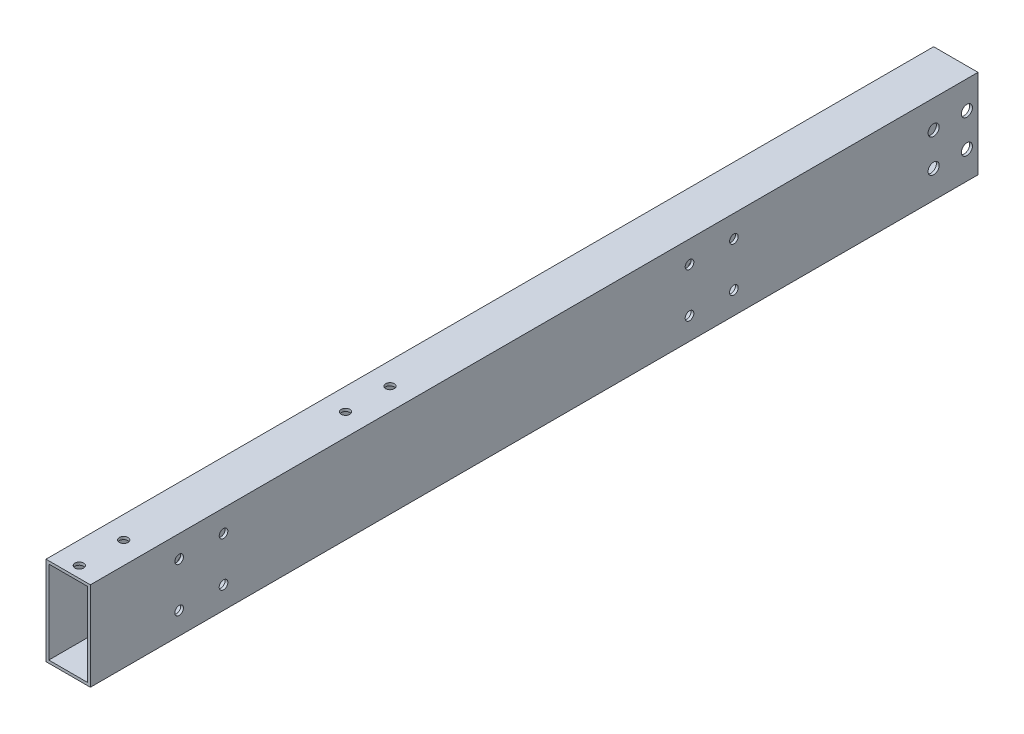
from build123d import *

# Parameters (mm, degrees)
SKETCH1_W           = 25.4
SKETCH1_H           = 50.8
SKETCH1_W_2         = 22.225
SKETCH1_H_2         = 47.625
EXTRUDE_THIN1_DEPTH = 508
SKETCH2_R           = 2.4765
CUT_EXTRUDE1_DEPTH  = 26.4
CUT_EXTRUDE2_REACH  = 52.8
SKETCH3_R           = 2.4892
CUT_EXTRUDE3_REACH  = 27.4
SKETCH4_R           = 3.175


with BuildPart() as part:
    # Sketch1 → Extrude-Thin1 (new body)
    with BuildSketch(Plane.XY):
        Rectangle(SKETCH1_W, SKETCH1_H)
        Rectangle(SKETCH1_W_2, SKETCH1_H_2, mode=Mode.SUBTRACT)
    extrude(amount=EXTRUDE_THIN1_DEPTH)

    # Sketch2 → Cut-Extrude1 (cut, through all)
    with BuildSketch(Plane(origin=(12.7, 0, 0), x_dir=(0, 0, -1), z_dir=(1, 0, 0))):
        with Locations((-457.2, 12.7)):
            Circle(SKETCH2_R)
        with Locations((-431.8, 12.7)):
            Circle(SKETCH2_R)
        with Locations((-431.8, -12.7)):
            Circle(SKETCH2_R)
        with Locations((-457.2, -12.7)):
            Circle(SKETCH2_R)
        with Locations((-165.1, 12.7)):
            Circle(SKETCH2_R)
        with Locations((-139.7, 12.7)):
            Circle(SKETCH2_R)
        with Locations((-139.7, -12.7)):
            Circle(SKETCH2_R)
        with Locations((-165.1, -12.7)):
            Circle(SKETCH2_R)
    extrude(amount=-CUT_EXTRUDE1_DEPTH, mode=Mode.SUBTRACT)

    # Sketch3 → Cut-Extrude2 (cut, up to next)
    with BuildSketch(Plane(origin=(0, 25.4, 0), x_dir=(1, 0, 0), z_dir=(0, 1, 0)), mode=Mode.PRIVATE) as cut_extrude2_sk1:
        with Locations((0, -323.85)):
            Circle(SKETCH3_R)
    cut_extrude2_tool1 = extrude(cut_extrude2_sk1.sketch, amount=-CUT_EXTRUDE2_REACH, mode=Mode.PRIVATE) & part.part
    add(cut_extrude2_tool1.solids().sort_by_distance((0, 25.4, 323.85))[0], mode=Mode.SUBTRACT)
    # Sketch3 → Cut-Extrude2 (cut, up to next)
    with BuildSketch(Plane(origin=(0, 25.4, 0), x_dir=(1, 0, 0), z_dir=(0, 1, 0)), mode=Mode.PRIVATE) as cut_extrude2_sk2:
        with Locations((0, -349.25)):
            Circle(SKETCH3_R)
    cut_extrude2_tool2 = extrude(cut_extrude2_sk2.sketch, amount=-CUT_EXTRUDE2_REACH, mode=Mode.PRIVATE) & part.part
    add(cut_extrude2_tool2.solids().sort_by_distance((0, 25.4, 349.25))[0], mode=Mode.SUBTRACT)
    # Sketch3 → Cut-Extrude2 (cut, up to next)
    with BuildSketch(Plane(origin=(0, 25.4, 0), x_dir=(1, 0, 0), z_dir=(0, 1, 0)), mode=Mode.PRIVATE) as cut_extrude2_sk3:
        with Locations((0, -476.25)):
            Circle(SKETCH3_R)
    cut_extrude2_tool3 = extrude(cut_extrude2_sk3.sketch, amount=-CUT_EXTRUDE2_REACH, mode=Mode.PRIVATE) & part.part
    add(cut_extrude2_tool3.solids().sort_by_distance((0, 25.4, 476.25))[0], mode=Mode.SUBTRACT)
    # Sketch3 → Cut-Extrude2 (cut, up to next)
    with BuildSketch(Plane(origin=(0, 25.4, 0), x_dir=(1, 0, 0), z_dir=(0, 1, 0)), mode=Mode.PRIVATE) as cut_extrude2_sk4:
        with Locations((0, -501.65)):
            Circle(SKETCH3_R)
    cut_extrude2_tool4 = extrude(cut_extrude2_sk4.sketch, amount=-CUT_EXTRUDE2_REACH, mode=Mode.PRIVATE) & part.part
    add(cut_extrude2_tool4.solids().sort_by_distance((0, 25.4, 501.65))[0], mode=Mode.SUBTRACT)

    # Sketch4 → Cut-Extrude3 (cut, up to next)
    with BuildSketch(Plane(origin=(12.7, 0, 0), x_dir=(0, 0, -1), z_dir=(1, 0, 0)), mode=Mode.PRIVATE) as cut_extrude3_sk1:
        with Locations((-25.4, 9.525)):
            Circle(SKETCH4_R)
    cut_extrude3_tool1 = extrude(cut_extrude3_sk1.sketch, amount=-CUT_EXTRUDE3_REACH, mode=Mode.PRIVATE) & part.part
    add(cut_extrude3_tool1.solids().sort_by_distance((12.7, 9.525, 25.4))[0], mode=Mode.SUBTRACT)
    # Sketch4 → Cut-Extrude3 (cut, up to next)
    with BuildSketch(Plane(origin=(12.7, 0, 0), x_dir=(0, 0, -1), z_dir=(1, 0, 0)), mode=Mode.PRIVATE) as cut_extrude3_sk2:
        with Locations((-6.35, 9.525)):
            Circle(SKETCH4_R)
    cut_extrude3_tool2 = extrude(cut_extrude3_sk2.sketch, amount=-CUT_EXTRUDE3_REACH, mode=Mode.PRIVATE) & part.part
    add(cut_extrude3_tool2.solids().sort_by_distance((12.7, 9.525, 6.35))[0], mode=Mode.SUBTRACT)
    # Sketch4 → Cut-Extrude3 (cut, up to next)
    with BuildSketch(Plane(origin=(12.7, 0, 0), x_dir=(0, 0, -1), z_dir=(1, 0, 0)), mode=Mode.PRIVATE) as cut_extrude3_sk3:
        with Locations((-6.35, -9.525)):
            Circle(SKETCH4_R)
    cut_extrude3_tool3 = extrude(cut_extrude3_sk3.sketch, amount=-CUT_EXTRUDE3_REACH, mode=Mode.PRIVATE) & part.part
    add(cut_extrude3_tool3.solids().sort_by_distance((12.7, -9.525, 6.35))[0], mode=Mode.SUBTRACT)
    # Sketch4 → Cut-Extrude3 (cut, up to next)
    with BuildSketch(Plane(origin=(12.7, 0, 0), x_dir=(0, 0, -1), z_dir=(1, 0, 0)), mode=Mode.PRIVATE) as cut_extrude3_sk4:
        with Locations((-25.4, -9.525)):
            Circle(SKETCH4_R)
    cut_extrude3_tool4 = extrude(cut_extrude3_sk4.sketch, amount=-CUT_EXTRUDE3_REACH, mode=Mode.PRIVATE) & part.part
    add(cut_extrude3_tool4.solids().sort_by_distance((12.7, -9.525, 25.4))[0], mode=Mode.SUBTRACT)


solid = part.part
